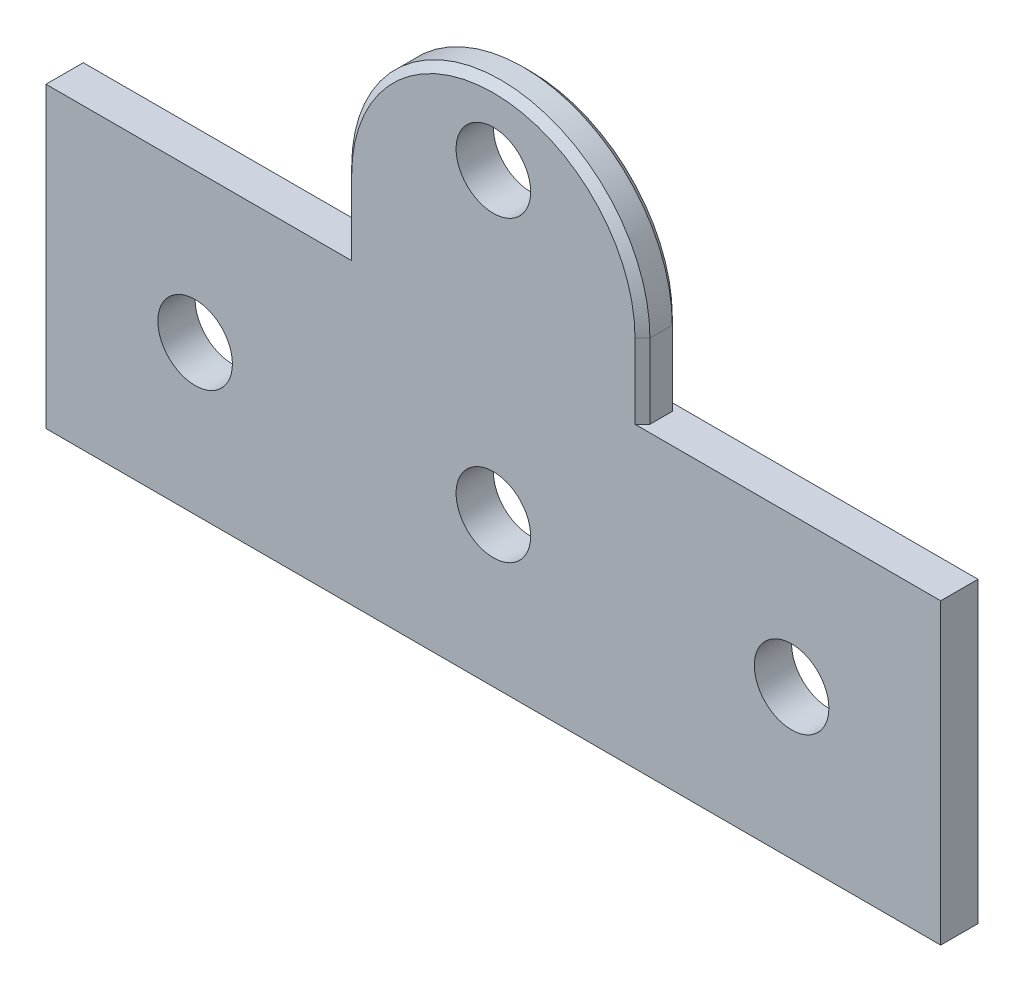
from build123d import *

# Parameters (mm, degrees)
SKETCH1_R           = 3.175
BOSS_EXTRUDE1_DEPTH = 3.175
CHAMFER2_SIZE       = 0.635


with BuildPart() as part:
    # Sketch1 → Boss-Extrude1 (new body)
    with BuildSketch(Plane.XY):
        with BuildLine():
            Line((0, 0), (25.4, 0))
            Line((25.4, 0), (50.8, 0))
            Line((50.8, 0), (50.8, 25.4))
            Line((50.8, 25.4), (25.4, 25.4))
            Line((25.4, 25.4), (25.4, 31.75))
            ThreePointArc((25.4, 31.75), (12.7, 44.45), (0, 31.75))
            Line((0, 31.75), (0, 25.4))
            Line((0, 25.4), (-25.4, 25.4))
            Line((-25.4, 25.4), (-25.4, 0))
            Line((-25.4, 0), (0, 0))
        make_face()
        with Locations((12.7, 38.1)):
            Circle(SKETCH1_R, mode=Mode.SUBTRACT)
        with Locations((12.7, 12.7)):
            Circle(SKETCH1_R, mode=Mode.SUBTRACT)
        with Locations((38.1, 12.7)):
            Circle(SKETCH1_R, mode=Mode.SUBTRACT)
        with Locations((-12.7, 12.7)):
            Circle(SKETCH1_R, mode=Mode.SUBTRACT)
    extrude(amount=BOSS_EXTRUDE1_DEPTH)

    # Chamfer2
    chamfer2_edges = [part.edges().sort_by_distance(p)[0] for p in [
        (0, 28.575, 0),
        (12.7, 44.45, 0),
        (25.4, 28.575, 0),
        (25.4, 28.575, 3.175),
        (12.7, 44.45, 3.175),
        (0, 28.575, 3.175),
    ]]
    chamfer(chamfer2_edges, length=CHAMFER2_SIZE)


solid = part.part
